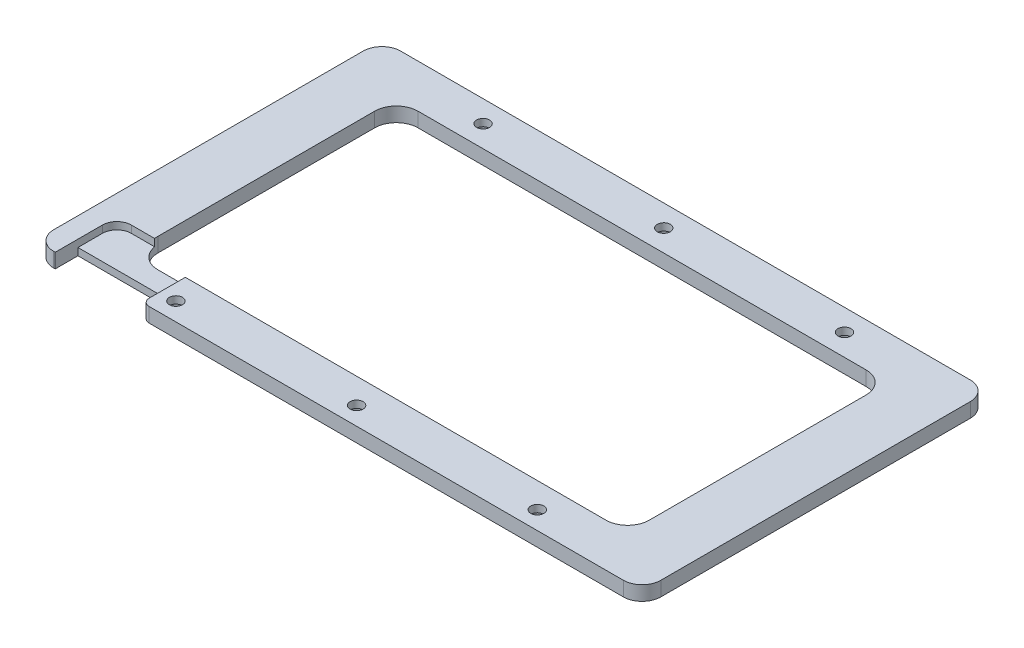
from build123d import *

# Parameters (mm, degrees)
SKETCH_1_R          = 0.9
EXTRUDE_1_DEPTH     = 2
SKETCH_8_W          = 12
SKETCH_8_H          = 10.026739303
CUT_EXTRUDE_4_DEPTH = 1
SKETCH_9_R          = 1.5
CUT_EXTRUDE_7_DEPTH = 1
FILLET_1_R          = 2
SKETCH_10_W         = 12
SKETCH_10_H         = 6.28269209
CUT_EXTRUDE_8_DEPTH = 2
FILLET_2_R          = 1


with BuildPart() as part:
    # 草图1 → 凸台-拉伸1 (new body)
    with BuildSketch(Plane(origin=(0, 0, 0), x_dir=(1, 0, 0), z_dir=(0, 1, 0))):
        with BuildLine():
            Line((-39.407613887, 24.257383456), (39.397836405, 24.257383456))
            ThreePointArc((39.397836405, 24.257383456), (41.234387067, 23.496659264), (41.995111259, 21.660108602))
            Line((41.995111259, 21.660108602), (41.995111259, -21.14534169))
            ThreePointArc((41.995111259, -21.14534169), (41.234387067, -22.981892352), (39.397836405, -23.742616544))
            Line((39.397836405, -23.742616544), (-39.407613887, -23.742616544))
            ThreePointArc((-39.407613887, -23.742616544), (-41.244164549, -22.981892352), (-42.004888741, -21.14534169))
            Line((-42.004888741, -21.14534169), (-42.004888741, 21.660108602))
            ThreePointArc((-42.004888741, 21.660108602), (-41.244164549, 23.496659264), (-39.407613887, 24.257383456))
        make_face()
        with Locations((-25.004888281, 21.257382356)):
            Circle(SKETCH_1_R, mode=Mode.SUBTRACT)
        with Locations((-0.004887481, 21.257382356)):
            Circle(SKETCH_1_R, mode=Mode.SUBTRACT)
        with Locations((24.995110779, 21.257382356)):
            Circle(SKETCH_1_R, mode=Mode.SUBTRACT)
        with Locations((24.995110779, -21.242616464)):
            Circle(SKETCH_1_R, mode=Mode.SUBTRACT)
        with Locations((-0.004887481, -21.242616464)):
            Circle(SKETCH_1_R, mode=Mode.SUBTRACT)
        with Locations((-25.004888281, -21.242616464)):
            Circle(SKETCH_1_R, mode=Mode.SUBTRACT)
        with BuildLine():
            Line((-31.004888741, 18.257383456), (30.995111259, 18.257383456))
            ThreePointArc((30.995111259, 18.257383456), (33.116431602, 17.3787038), (33.995111259, 15.257383456))
            Line((33.995111259, 15.257383456), (33.995111259, -14.742616544))
            ThreePointArc((33.995111259, -14.742616544), (33.116431602, -16.863936887), (30.995111259, -17.742616544))
            Line((30.995111259, -17.742616544), (-31.004888741, -17.742616544))
            ThreePointArc((-31.004888741, -17.742616544), (-33.126209085, -16.863936887), (-34.004888741, -14.742616544))
            Line((-34.004888741, -14.742616544), (-34.004888741, 15.257383456))
            ThreePointArc((-34.004888741, 15.257383456), (-33.126209085, 17.3787038), (-31.004888741, 18.257383456))
        make_face(mode=Mode.SUBTRACT)
    extrude(amount=EXTRUDE_1_DEPTH)

    # 草图8 → 切除-拉伸4 (cut)
    with BuildSketch(Plane(origin=(0, 2, 0), x_dir=(1, 0, 0), z_dir=(0, 1, 0))):
        with Locations((-33.2, -20.228282189)):
            Rectangle(SKETCH_8_W, SKETCH_8_H)
    extrude(amount=-CUT_EXTRUDE_4_DEPTH, mode=Mode.SUBTRACT)

    # 草图9 → 切除-拉伸7 (cut)
    with BuildSketch(Plane.XZ):
        with Locations((-25.004888281, 21.242616464)):
            Circle(SKETCH_9_R)
        with Locations((-0.004887481, 21.242616464)):
            Circle(SKETCH_9_R)
        with Locations((24.995110779, 21.242616464)):
            Circle(SKETCH_9_R)
        with Locations((-25.004888281, -21.257382356)):
            Circle(SKETCH_9_R)
        with Locations((-0.004887481, -21.257382356)):
            Circle(SKETCH_9_R)
        with Locations((24.995110779, -21.257382356)):
            Circle(SKETCH_9_R)
    extrude(amount=-CUT_EXTRUDE_7_DEPTH, mode=Mode.SUBTRACT)

    # 圆角1
    fillet_1_edges = [part.edges().sort_by_distance(p)[0] for p in [
        (-39.2, 1.5, 15.214912538),
    ]]
    fillet(fillet_1_edges, radius=FILLET_1_R)

    # 草图10 → 切除-拉伸8 (cut, through all)
    with BuildSketch(Plane(origin=(0, 1, 0), x_dir=(1, 0, 0), z_dir=(0, 1, 0))):
        with Locations((-33.2, -23.742616544)):
            Rectangle(SKETCH_10_W, SKETCH_10_H)
    extrude(amount=-CUT_EXTRUDE_8_DEPTH, mode=Mode.SUBTRACT)

    # 圆角2
    fillet_2_edges = [part.edges().sort_by_distance(p)[0] for p in [
        (-27.2, 1, 23.742616544),
    ]]
    fillet(fillet_2_edges, radius=FILLET_2_R)


solid = part.part
